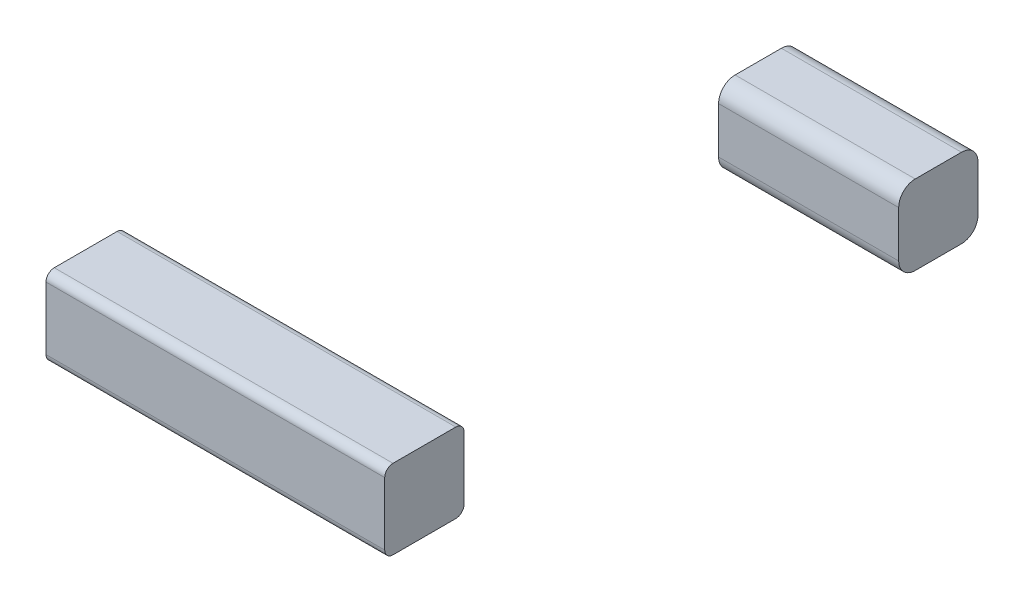
from build123d import *

# Parameters (mm, degrees)
SKETCH_1_R          = 4.9
SKETCH_1_W          = 5
SKETCH_1_H          = 5
EXTRUDE_1_DEPTH     = 5
SKETCH_2_W          = 10
SKETCH_2_H          = 5
EXTRUDE_2_DEPTH     = 5
SKETCH_3_R          = 5.914940822
CUT_EXTRUDE_1_DEPTH = 10
CUT_EXTRUDE_2_DEPTH = 10
SKETCH_5_W          = 4.8
SKETCH_5_H          = 4.8
EXTRUDE_3_DEPTH     = 10
SKETCH_5_W_2        = 4.6
SKETCH_5_H_2        = 4.6
EXTRUDE_3_2_DEPTH   = 10
SKETCH_5_W_3        = 4.5
SKETCH_5_H_3        = 4.5
EXTRUDE_3_3_DEPTH   = 10
FILLET_1_R          = 0.5
FILLET_2_R          = 0.5
FILLET_3_R          = 0.5
FILLET_4_R          = 0.5
SKETCH_6_W          = 4.9
SKETCH_6_H          = 4.9
EXTRUDE_4_DEPTH     = 20.5
FILLET_5_R          = 1
EXTRUDE_5_DEPTH     = 10.5
SKETCH_9_R          = 3.402598628
CUT_EXTRUDE_3_DEPTH = 10.5
SKETCH_10_R         = 4.357418538
CUT_EXTRUDE_4_DEPTH = 10.5
SKETCH_11_R         = 4.197019633
CUT_EXTRUDE_5_DEPTH = 100.5
SKETCH_12_W         = 4.8
SKETCH_12_H         = 4.8
EXTRUDE_6_DEPTH     = 10.9
FILLET_6_R          = 1


with BuildPart() as part:
    # 草图1 → 凸台-拉伸1 (new body)
    with BuildSketch(Plane(origin=(0, 0, 0), x_dir=(1, 0, 0), z_dir=(0, 1, 0))):
        with Locations((-9.777161154, 17.932244479)):
            Circle(SKETCH_1_R)
        with Locations((-9.777161154, 17.932244479)):
            Rectangle(SKETCH_1_W, SKETCH_1_H, mode=Mode.SUBTRACT)
    extrude(amount=EXTRUDE_1_DEPTH)

    # 草图3 → 切除-拉伸1 (cut)
    with BuildSketch(Plane(origin=(0, 5, 0), x_dir=(1, 0, 0), z_dir=(0, 1, 0))):
        with Locations((-9.777161154, 17.932244479)):
            Circle(SKETCH_3_R)
    extrude(amount=-CUT_EXTRUDE_1_DEPTH, mode=Mode.SUBTRACT)


with BuildPart() as body_2:
    # 草图2 → 凸台-拉伸2 (new body)
    with BuildSketch(Plane(origin=(0, 0, 0), x_dir=(1, 0, 0), z_dir=(0, 1, 0))):
        with Locations((-15.49352073, 27.026927295)):
            Rectangle(SKETCH_2_W, SKETCH_2_H)
    extrude(amount=EXTRUDE_2_DEPTH)

    # 草图4 → 切除-拉伸2 (cut)
    with BuildSketch(Plane.ZY.offset(20.49352073)):
        Polygon((-29.526927295, 4.9), (-29.526927295, 5), (-24.526927295, 5), (-24.526927295, 0), (-24.626927295, 0), (-24.626927295, 4.9), align=None)
    extrude(amount=-CUT_EXTRUDE_2_DEPTH, mode=Mode.SUBTRACT)

    # 圆角1
    fillet_1_edges = [body_2.edges().sort_by_distance(p)[0] for p in [
        (-15.49352073, 0, -24.626927295),
        (-15.49352073, 4.9, -24.626927295),
        (-15.49352073, 4.9, -29.526927295),
        (-15.49352073, 0, -29.526927295),
    ]]
    fillet(fillet_1_edges, radius=FILLET_1_R)

    # 草图6 → 凸台-拉伸4 (add)
    with BuildSketch(Plane(origin=(-10.49352073, 0, 0), x_dir=(0, 0, -1), z_dir=(1, 0, 0))):
        with Locations((27.076927295, 2.45)):
            Rectangle(SKETCH_6_W, SKETCH_6_H)
    extrude(amount=EXTRUDE_4_DEPTH)

    # 圆角5
    fillet_5_edges = [body_2.edges().sort_by_distance(p)[0] for p in [
        (-0.24352073, 0, -24.626927295),
        (-0.24352073, 4.9, -29.526927295),
        (-0.24352073, 0, -29.526927295),
        (-0.24352073, 4.9, -24.626927295),
    ]]
    fillet(fillet_5_edges, radius=FILLET_5_R)

    # 草图11 → 切除-拉伸5 (cut)
    with BuildSketch(Plane.ZY.offset(20.49352073)):
        with Locations((-27.149876741, 2.428663145)):
            Circle(SKETCH_11_R)
    extrude(amount=-CUT_EXTRUDE_5_DEPTH, mode=Mode.SUBTRACT)


with BuildPart() as body_2_2:
    # 草图5 → 凸台-拉伸3 (new body)
    with BuildSketch(Plane(origin=(0, 0, 0), x_dir=(0, 0, -1), z_dir=(1, 0, 0))):
        with Locations((35.124788923, 2.4)):
            Rectangle(SKETCH_5_W, SKETCH_5_H)
    extrude(amount=EXTRUDE_3_DEPTH)

    # 圆角2
    fillet_2_edges = [body_2_2.edges().sort_by_distance(p)[0] for p in [
        (5, 4.8, -32.724788923),
        (5, 4.8, -37.524788923),
        (5, 0, -37.524788923),
        (5, 0, -32.724788923),
    ]]
    fillet(fillet_2_edges, radius=FILLET_2_R)

    # 草图8 → 凸台-拉伸5 (add)
    with BuildSketch(Plane.ZY):
        with BuildLine():
            Line((-33.224788923, 4.8), (-37.024788923, 4.8))
            ThreePointArc((-37.024788923, 4.8), (-37.378342314, 4.653553391), (-37.524788923, 4.3))
            Line((-37.524788923, 4.3), (-37.524788923, 0.5))
            ThreePointArc((-37.524788923, 0.5), (-37.378342314, 0.146446609), (-37.024788923, 0))
            Line((-37.024788923, 0), (-33.224788923, 0))
            ThreePointArc((-33.224788923, 0), (-32.871235532, 0.146446609), (-32.724788923, 0.5))
            Line((-32.724788923, 0.5), (-32.724788923, 4.3))
            ThreePointArc((-32.724788923, 4.3), (-32.871235532, 4.653553391), (-33.224788923, 4.8))
        make_face()
    extrude(amount=EXTRUDE_5_DEPTH)


with BuildPart() as body_3:
    # 草图5 → Extrude 3 2 (new body)
    with BuildSketch(Plane(origin=(0, 0, 0), x_dir=(0, 0, -1), z_dir=(1, 0, 0))):
        with Locations((43.904383403, 2.3)):
            Rectangle(SKETCH_5_W_2, SKETCH_5_H_2)
    extrude(amount=EXTRUDE_3_2_DEPTH)

    # 圆角3
    fillet_3_edges = [body_3.edges().sort_by_distance(p)[0] for p in [
        (5, 4.6, -41.604383403),
        (5, 4.6, -46.204383403),
        (5, 0, -46.204383403),
        (5, 0, -41.604383403),
    ]]
    fillet(fillet_3_edges, radius=FILLET_3_R)

    # 草图10 → 切除-拉伸4 (cut)
    with BuildSketch(Plane.ZY):
        with Locations((-43.711928748, 2.423135274)):
            Circle(SKETCH_10_R)
    extrude(amount=-CUT_EXTRUDE_4_DEPTH, mode=Mode.SUBTRACT)


with BuildPart() as body_4:
    # 草图5 → Extrude 3 3 (new body)
    with BuildSketch(Plane(origin=(0, 0, 0), x_dir=(0, 0, -1), z_dir=(1, 0, 0))):
        with Locations((50.920405069, 2.25)):
            Rectangle(SKETCH_5_W_3, SKETCH_5_H_3)
    extrude(amount=EXTRUDE_3_3_DEPTH)

    # 圆角4
    fillet_4_edges = [body_4.edges().sort_by_distance(p)[0] for p in [
        (5, 4.5, -48.670405069),
        (5, 4.5, -53.170405069),
        (5, 0, -53.170405069),
        (5, 0, -48.670405069),
    ]]
    fillet(fillet_4_edges, radius=FILLET_4_R)

    # 草图9 → 切除-拉伸3 (cut)
    with BuildSketch(Plane.ZY):
        with Locations((-50.9868081, 2.355561391)):
            Circle(SKETCH_9_R)
    extrude(amount=-CUT_EXTRUDE_3_DEPTH, mode=Mode.SUBTRACT)


with BuildPart() as body_2_3:
    # 草图12 → 凸台-拉伸6 (new body)
    with BuildSketch(Plane(origin=(0, 0, 0), x_dir=(0, 0, -1), z_dir=(1, 0, 0))):
        with Locations((65.330249397, 2.4)):
            Rectangle(SKETCH_12_W, SKETCH_12_H)
    extrude(amount=EXTRUDE_6_DEPTH)

    # 圆角6
    fillet_6_edges = [body_2_3.edges().sort_by_distance(p)[0] for p in [
        (5.45, 4.8, -62.930249397),
        (5.45, 4.8, -67.730249397),
        (5.45, 0, -67.730249397),
        (5.45, 0, -62.930249397),
    ]]
    fillet(fillet_6_edges, radius=FILLET_6_R)


solid = Compound([body_2_2.part, body_2_3.part])
